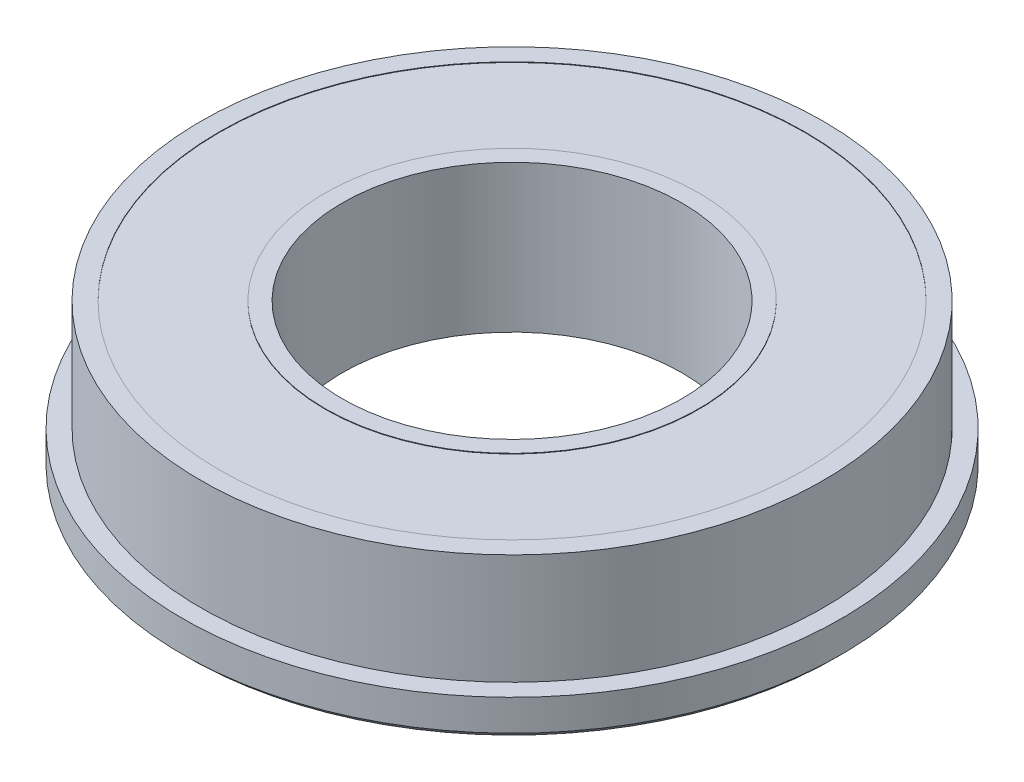
from build123d import *

# Parameters (mm, degrees)
CHAMFER1_SIZE = 0.5


with BuildPart() as part:
    # Sketch1 → Revolve1 (revolve)
    with BuildSketch(Plane.XY):
        Polygon((15, 0), (16.512706206, 0), (16.512706206, 0.048438063), (25.873387513, 0.048438063), (25.873387513, 0), (29.125, 0), (29.125, 3.25), (27.5, 3.25), (27.5, 13), (25.873387513, 13), (25.873387513, 12.951561937), (16.512706206, 12.951561937), (16.512706206, 13), (15, 13), align=None)
    revolve(axis=Axis((0, 0, 0), (0, 1, 0)))

    # Chamfer1
    chamfer1_edges = [part.edges().sort_by_distance(p)[0] for p in [
        (-29.125, 0, 0),
    ]]
    chamfer(chamfer1_edges, length=CHAMFER1_SIZE)


solid = part.part
